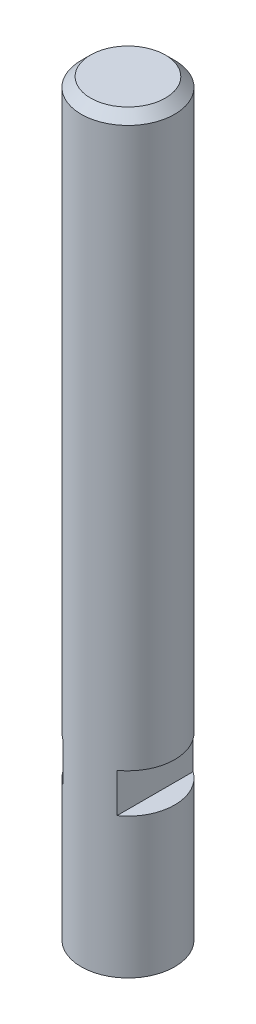
from build123d import *

# Parameters (mm, degrees)
SKIZZE1_W                       = 5
SKIZZE1_H                       = 80
M4_GEWINDEBOHRUNG1_D            = 3.3
M4_GEWINDEBOHRUNG1_DEPTH        = 40
M4_GEWINDEBOHRUNG1_TIP          = 0.991420021
SKIZZE5_W                       = 4.2
SKIZZE5_H                       = 4.2
SCHNITT_LINEAR_AUSTRAGEN1_DEPTH = 10
FASE1_SIZE                      = 1


with BuildPart() as part:
    # Skizze1 → Rotation1 (revolve)
    with BuildSketch(Plane(origin=(0, 0, 0), x_dir=(0, 0, -1), z_dir=(1, 0, 0))):
        with Locations((-2.5, 40)):
            Rectangle(SKIZZE1_W, SKIZZE1_H)
    revolve(axis=Axis((0, 0, 0), (0, -1, 0)))

    # M4 Gewindebohrung1
    with Locations(Plane(origin=(0, 0, 0), x_dir=(-1, 0, 0), z_dir=(0, -1, 0))):
        with Locations((0, 0)):
            Hole(M4_GEWINDEBOHRUNG1_D / 2, depth=M4_GEWINDEBOHRUNG1_DEPTH)
            with Locations((0, 0, -(M4_GEWINDEBOHRUNG1_DEPTH + M4_GEWINDEBOHRUNG1_TIP / 2))):  # 118° drill point
                Cone(0, M4_GEWINDEBOHRUNG1_D / 2, M4_GEWINDEBOHRUNG1_TIP, mode=Mode.SUBTRACT)

    # Skizze5 → Schnitt-Linear austragen1 (cut, symmetric)
    with BuildSketch(Plane.XY):
        with Locations((-5, 17.1)):
            Rectangle(SKIZZE5_W, SKIZZE5_H)
    schnitt_linear_austragen1 = extrude(amount=SCHNITT_LINEAR_AUSTRAGEN1_DEPTH, both=True, mode=Mode.SUBTRACT)

    # Spiegeln1: Schnitt-Linear austragen1 across plane
    add(schnitt_linear_austragen1.mirror(Plane(origin=(0, 0, 0), x_dir=(0, 0, 1), z_dir=(1, 0, 0))), mode=Mode.SUBTRACT)

    # Fase1
    fase1_edges = [part.edges().sort_by_distance(p)[0] for p in [
        (0, 80, -5),
    ]]
    chamfer(fase1_edges, length=FASE1_SIZE)


solid = part.part
